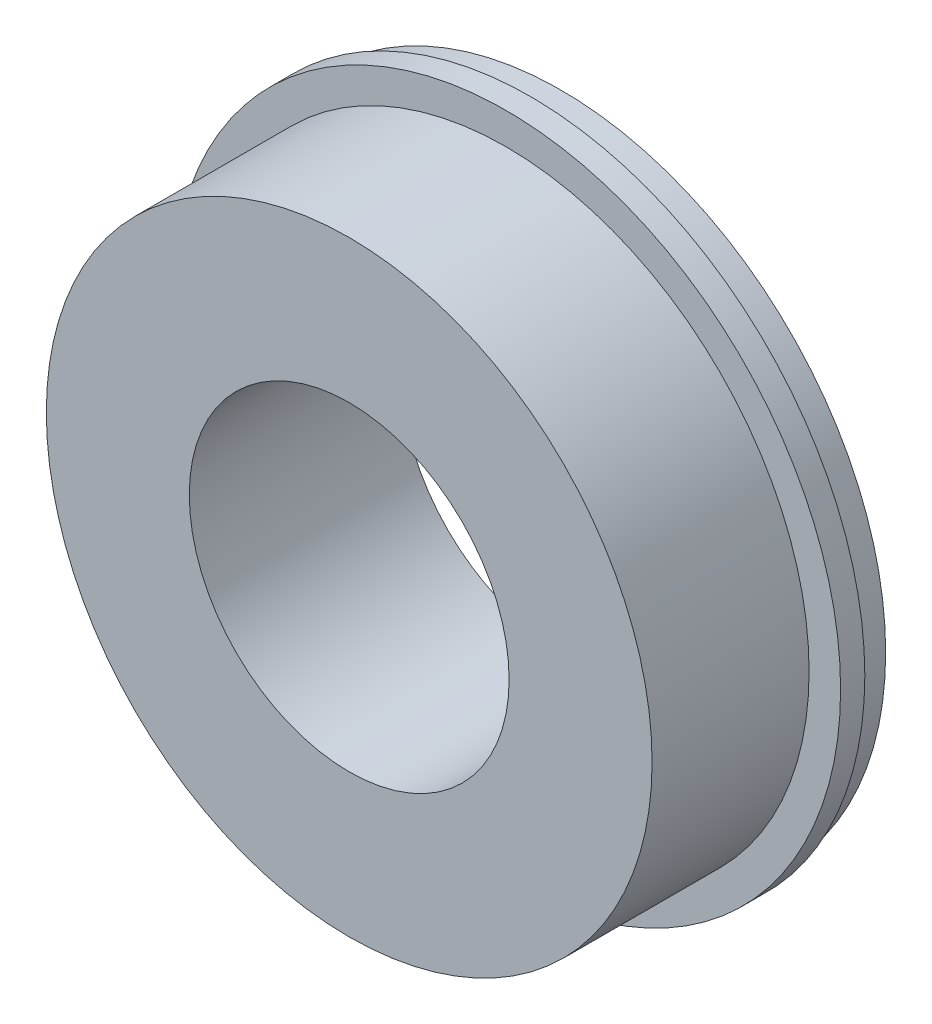
from build123d import *

# Parameters (mm, degrees)
SKETCH1_R           = 70
BOSS_EXTRUDE1_DEPTH = 40
SKETCH3_W           = 6.5
SKETCH3_H           = 32.4
SKETCH5_W           = 9.259396931
SKETCH5_H           = 5.5
SKETCH6_W           = 156.018137672
SKETCH6_H           = 46.428345924
CUT_EXTRUDE1_DEPTH  = 81


with BuildPart() as part:
    # Sketch1 → Boss-Extrude1 (new body, symmetric)
    with BuildSketch(Plane.XY):
        Circle(SKETCH1_R)
    extrude(amount=BOSS_EXTRUDE1_DEPTH, both=True)

    # Sketch2 → Cut-Revolve1 (revolve, cut)
    with BuildSketch(Plane(origin=(0, 0, 0), x_dir=(1, 0, 0), z_dir=(0, 1, 0))):
        Polygon((-69, 40), (-69, 35), (-67, 35), (-67, 28.7), (-60, 28.7), (-60, 3.7), (-67, 3.7), (-67, -2.6), (-69, -2.6), (-69, -44.705491592), (-73.643536697, -44.705491592), (-73.643536697, 40), align=None)
    revolve(axis=Axis((0, 0, 0), (0, 0, -1)), mode=Mode.SUBTRACT)

    # Sketch3 → Cut-Revolve2 (revolve, cut)
    with BuildSketch(Plane(origin=(0, 0, 0), x_dir=(1, 0, 0), z_dir=(0, 1, 0))):
        with Locations((-65.75, -23.8)):
            Rectangle(SKETCH3_W, SKETCH3_H)
    revolve(axis=Axis((0, 0, 0), (0, 0, 1)), mode=Mode.SUBTRACT)

    # Sketch4 → Cut-Revolve3 (revolve, cut)
    with BuildSketch(Plane(origin=(0, 0, 0), x_dir=(1, 0, 0), z_dir=(0, 1, 0))):
        Polygon((0, 42.623044552), (-37.5, 42.623044552), (-37.5, 20), (-33, 20), (-33, -40), (0, -40), align=None)
    revolve(axis=Axis((0, 0, 0), (0, 0, -1)), mode=Mode.SUBTRACT)

    # Sketch5 → Cut-Revolve4 (revolve, cut)
    with BuildSketch(Plane(origin=(0, 0, 0), x_dir=(1, 0, 0), z_dir=(0, 1, 0))):
        with Locations((-37.620301535, 32.25)):
            Rectangle(SKETCH5_W, SKETCH5_H)
    revolve(axis=Axis((0, 0, 0), (0, 0, -1)), mode=Mode.SUBTRACT)

    # Sketch6 → Cut-Extrude1 (cut, symmetric)
    with BuildSketch(Plane(origin=(0, 0, 0), x_dir=(1, 0, 0), z_dir=(0, 1, 0))):
        with Locations((-2.837222121, 26.914172962)):
            Rectangle(SKETCH6_W, SKETCH6_H)
    extrude(amount=CUT_EXTRUDE1_DEPTH, both=True, mode=Mode.SUBTRACT)


solid = part.part
